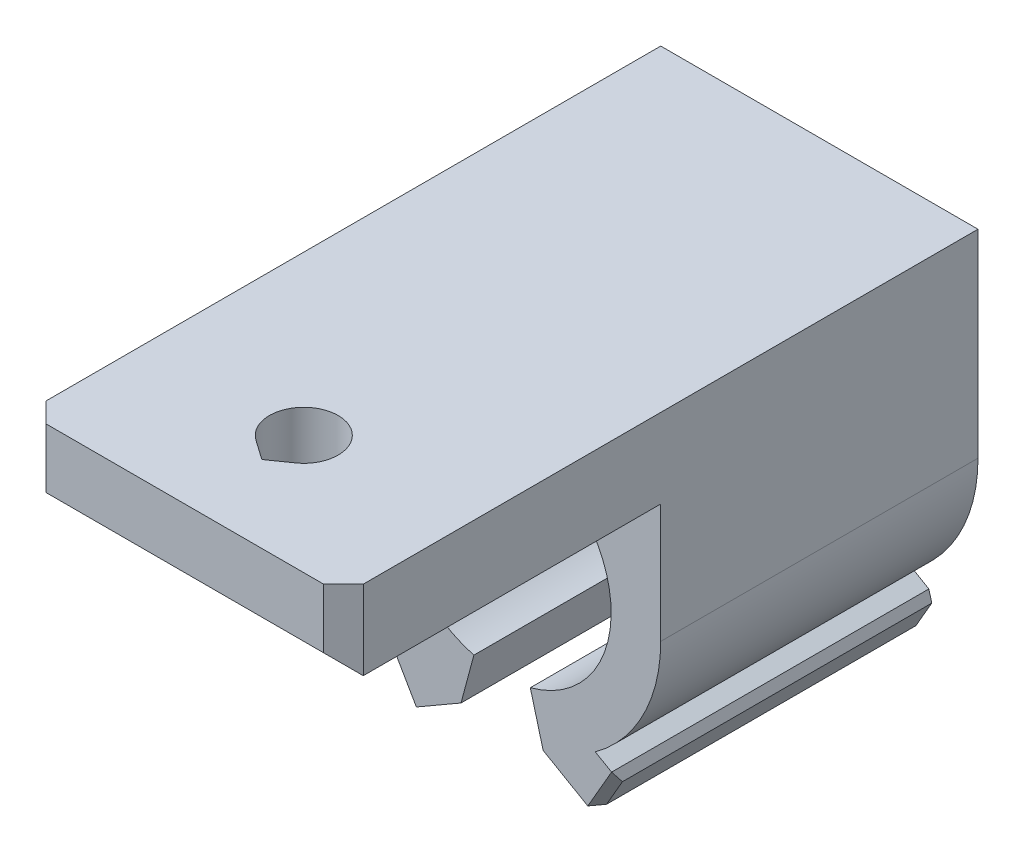
from build123d import *

# Parameters (mm, degrees)
CLIP_DEPTH        = 20.32
SKETCH1_3_W       = 20.32
SKETCH1_3_H       = 5.08
BACK_DEPTH        = 40.64
HOLE_DEPTH        = 47.139187604
COUNTERBORE_DEPTH = 1.397
CHAMFER1_SIZE     = 1.27
CHAMFER2_SIZE     = 0.508


with BuildPart() as part:
    # Sketch1 → clip (new body)
    with BuildSketch(Plane.XY):
        with BuildLine():
            Line((-2.629601498, -9.813806395), (-1.80785103, -6.746991897))
            ThreePointArc((-1.80785103, -6.746991897), (0, 6.985), (1.80785103, -6.746991897))
            Line((1.80785103, -6.746991897), (2.629601498, -9.813806395))
            Line((2.629601498, -9.813806395), (5.929158287, -11.718806395))
            Line((5.929158287, -11.718806395), (7.453158287, -9.079160964))
            Line((7.453158287, -9.079160964), (5.96856706, -8.22203182))
            ThreePointArc((5.96856706, -8.22203182), (9.051691591, -4.614377459), (10.16, 0))
            Line((10.16, 0), (10.16, 12.7))
            Line((10.16, 12.7), (-10.16, 12.7))
            Line((-10.16, 12.7), (-10.16, 0))
            ThreePointArc((-10.16, 0), (-9.051691591, -4.614377459), (-5.96856706, -8.22203182))
            Line((-5.96856706, -8.22203182), (-7.453158287, -9.079160964))
            Line((-7.453158287, -9.079160964), (-5.929158287, -11.718806395))
            Line((-5.929158287, -11.718806395), (-2.629601498, -9.813806395))
        make_face()
    extrude(amount=CLIP_DEPTH)

    # Sketch1_3 → back (add)
    with BuildSketch(Plane.XY):
        with Locations((0, 10.16)):
            Rectangle(SKETCH1_3_W, SKETCH1_3_H)
    extrude(amount=BACK_DEPTH)

    # Sketch4 → hole (cut, through all)
    with BuildSketch(Plane.XZ.offset(-7.62)):
        with BuildLine():
            Line((1.26186816, 34.822134497), (0, 35.705704095))
            Line((0, 35.705704095), (-1.26186816, 34.822134497))
            ThreePointArc((-1.26186816, 34.822134497), (0, 30.82), (1.26186816, 34.822134497))
        make_face()
    extrude(amount=-HOLE_DEPTH, mode=Mode.SUBTRACT)

    # Sketch4_3 → counterbore (cut)
    with BuildSketch(Plane.XZ.offset(-7.62)):
        with BuildLine():
            Line((2.3660028, 36.399002183), (0, 38.055695179))
            Line((0, 38.055695179), (-2.3660028, 36.399002183))
            ThreePointArc((-2.3660028, 36.399002183), (0, 28.895), (2.3660028, 36.399002183))
        make_face()
        with BuildLine():
            Line((-1.26186816, 34.822134497), (0, 35.705704095))
            Line((0, 35.705704095), (1.26186816, 34.822134497))
            ThreePointArc((1.26186816, 34.822134497), (0, 30.82), (-1.26186816, 34.822134497))
        make_face(mode=Mode.SUBTRACT)
    extrude(amount=-COUNTERBORE_DEPTH, mode=Mode.SUBTRACT)

    # Chamfer1
    chamfer1_edges = [part.edges().sort_by_distance(p)[0] for p in [
        (-10.16, 10.16, 40.64),
        (10.16, 10.16, 40.64),
        (0, 7.62, 40.64),
    ]]
    chamfer(chamfer1_edges, length=CHAMFER1_SIZE)

    # Chamfer2
    chamfer2_edges = [part.edges().sort_by_distance(p)[0] for p in [
        (7.453158287, -9.079160964, 10.16),
        (5.929158287, -11.718806395, 10.16),
        (6.691158287, -10.39898368, 20.32),
        (-7.453158287, -9.079160964, 10.16),
        (-5.929158287, -11.718806395, 10.16),
        (-6.691158287, -10.39898368, 20.32),
    ]]
    chamfer(chamfer2_edges, length=CHAMFER2_SIZE)


solid = part.part
